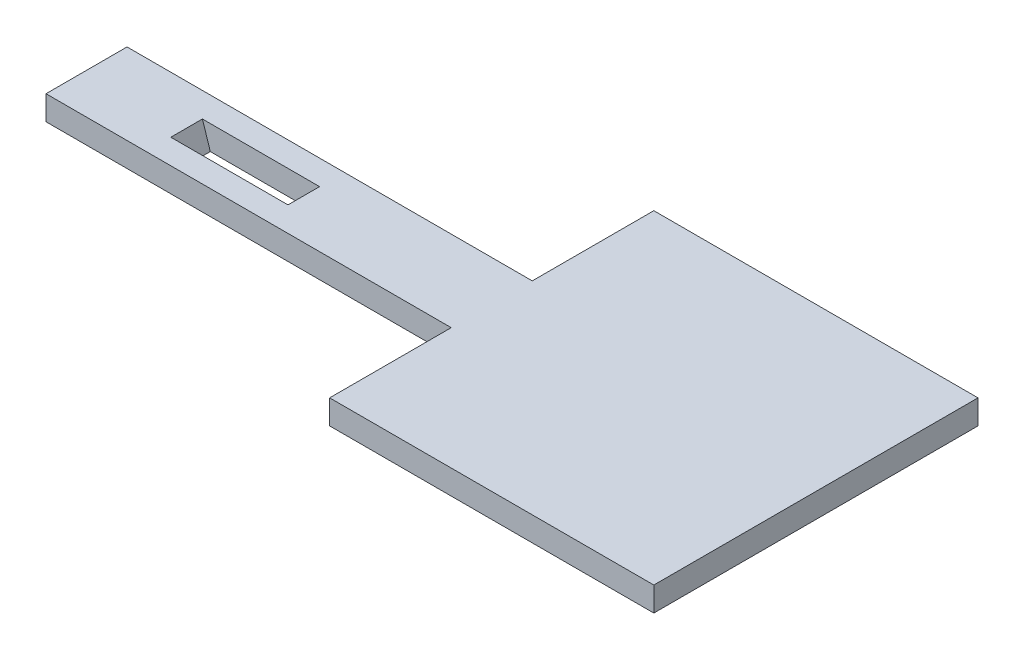
from build123d import *

# Parameters (mm, degrees)
EXTRUDE_1_DEPTH     = 3
CUT_EXTRUDE_START   = -5
CUT_EXTRUDE_1_DEPTH = 1.95


with BuildPart() as part:
    # 草圖1 → 填料-伸長1 (new body)
    with BuildSketch(Plane(origin=(0, 0, 0), x_dir=(1, 0, 0), z_dir=(0, 1, 0))):
        Polygon((22, 5.315789474), (22, 20.315789474), (62, 20.315789474), (62, -19.684210526), (22, -19.684210526), (22, -4.684210526), (-28, -4.684210526), (-28, 5.315789474), align=None)
    extrude(amount=EXTRUDE_1_DEPTH)

    # 草圖3 → 除料-伸長1 (cut, symmetric)
    with BuildSketch(Plane.XY.offset(4.684210526).offset(CUT_EXTRUDE_START)):
        Polygon((-15.649759089, 3), (-1.192153505, 3), (-0.217394417, 0), (-14.675, 0), align=None)
    extrude(amount=CUT_EXTRUDE_1_DEPTH, both=True, mode=Mode.SUBTRACT)


solid = part.part
